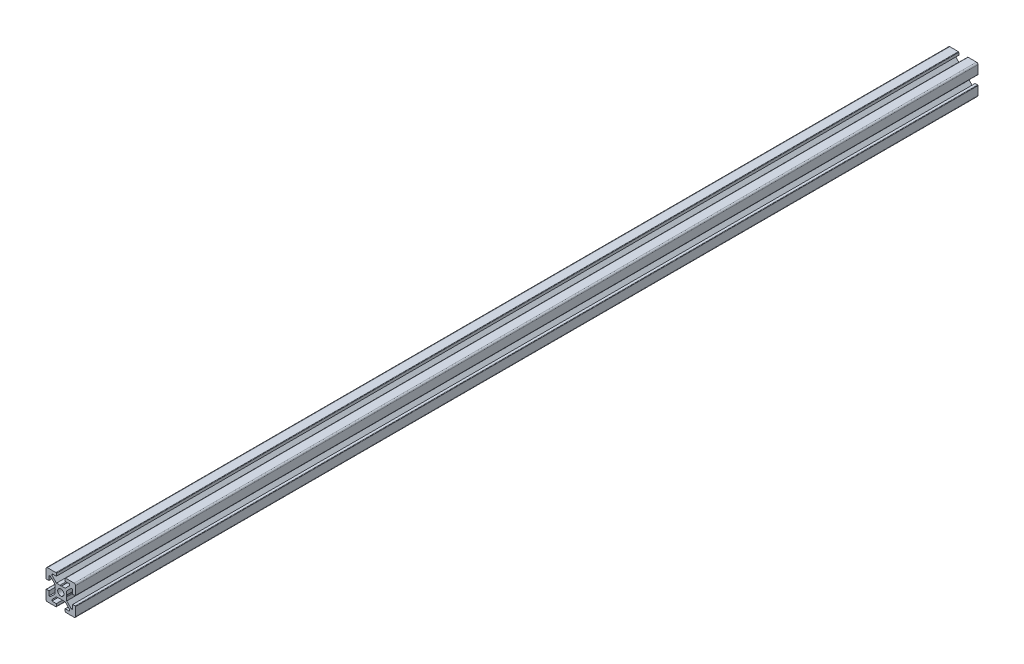
from build123d import *

# Parameters (mm, degrees)
BOSS_EXTRUDE1_DEPTH     = 609.5
SKETCH2_W               = 609.5
SKETCH2_H               = 2.1
SKETCH4_R               = 2.5
CUT_EXTRUDE1_DEPTH      = 10
CUT_EXTRUDE1_DEPTH_BACK = 10
SKETCH6_R               = 2.5
CUT_EXTRUDE2_DEPTH      = 10
CUT_EXTRUDE2_DEPTH_BACK = 10


with BuildPart() as part:
    # Sketch1 → Boss-Extrude1 (new body)
    with BuildSketch(Plane.XY):
        with BuildLine():
            Line((-10, 9), (-10, 3.29999995))
            ThreePointArc((-10, 3.29999995), (-9.912132049, 3.087867916), (-9.7, 3))
            Line((-9.7, 3), (-8, 3))
            Line((-8, 3), (-8, 6))
            Line((-8, 6), (-7.060677, 6))
            Line((-7.060677, 6), (-4, 2.93932965))
            Line((-4, 2.93932965), (-4, 0.519615242))
            Line((-4, 0.519615242), (-3.699996283, -6.437e-06))
            Line((-3.699996283, -6.437e-06), (-4, -0.519628117))
            Line((-4, -0.519628117), (-4, -2.93933725))
            Line((-4, -2.93933725), (-7.0606695, -6))
            Line((-7.0606695, -6), (-8, -6))
            Line((-8, -6), (-8, -3))
            Line((-8, -3), (-9.7, -3))
            ThreePointArc((-9.7, -3), (-9.912132049, -3.087867916), (-10, -3.29999995))
            Line((-10, -3.29999995), (-10, -9))
            ThreePointArc((-10, -9), (-9.707106781, -9.707106781), (-9, -10))
            Line((-9, -10), (-3.29999995, -10))
            ThreePointArc((-3.29999995, -10), (-3.087867916, -9.912132049), (-3, -9.7))
            Line((-3, -9.7), (-3, -8))
            Line((-3, -8), (-6, -8))
            Line((-6, -8), (-6, -7.0606515))
            Line((-6, -7.0606515), (-2.9393489, -4))
            Line((-2.9393489, -4), (-0.519615242, -4))
            Line((-0.519615242, -4), (6.437e-06, -3.699996283))
            Line((6.437e-06, -3.699996283), (0.519628117, -4))
            Line((0.519628117, -4), (2.9393227, -4))
            Line((2.9393227, -4), (6, -7.060677))
            Line((6, -7.060677), (6, -8))
            Line((6, -8), (3, -8))
            Line((3, -8), (3, -9.7))
            ThreePointArc((3, -9.7), (3.087867916, -9.912132049), (3.29999995, -10))
            Line((3.29999995, -10), (9, -10))
            ThreePointArc((9, -10), (9.707106781, -9.707106781), (10, -9))
            Line((10, -9), (10, -3.29999995))
            ThreePointArc((10, -3.29999995), (9.912132049, -3.087867916), (9.7, -3))
            Line((9.7, -3), (8, -3))
            Line((8, -3), (8, -6))
            Line((8, -6), (7.0606435, -6))
            Line((7.0606435, -6), (4, -2.9393482))
            Line((4, -2.9393482), (4, -0.519615242))
            Line((4, -0.519615242), (3.699996283, 6.437e-06))
            Line((3.699996283, 6.437e-06), (4, 0.519628117))
            Line((4, 0.519628117), (4, 2.9393401))
            Line((4, 2.9393401), (7.060651, 6))
            Line((7.060651, 6), (8, 6))
            Line((8, 6), (8, 3))
            Line((8, 3), (9.7, 3))
            ThreePointArc((9.7, 3), (9.912132049, 3.087867916), (10, 3.29999995))
            Line((10, 3.29999995), (10, 9))
            ThreePointArc((10, 9), (9.707106781, 9.707106781), (9, 10))
            Line((9, 10), (3.29999995, 10))
            ThreePointArc((3.29999995, 10), (3.087867916, 9.912132049), (3, 9.7))
            Line((3, 9.7), (3, 8))
            Line((3, 8), (6, 8))
            Line((6, 8), (6, 7.060669))
            Line((6, 7.060669), (2.9393308, 4))
            Line((2.9393308, 4), (0.519615242, 4))
            Line((0.519615242, 4), (-6.437e-06, 3.699996283))
            Line((-6.437e-06, 3.699996283), (-0.519628117, 4))
            Line((-0.519628117, 4), (-2.93935655, 4))
            Line((-2.93935655, 4), (-6, 7.0606435))
            Line((-6, 7.0606435), (-6, 8))
            Line((-6, 8), (-3, 8))
            Line((-3, 8), (-3, 9.7))
            ThreePointArc((-3, 9.7), (-3.087867966, 9.912132034), (-3.3, 10))
            Line((-3.3, 10), (-9, 10))
            ThreePointArc((-9, 10), (-9.707106781, 9.707106781), (-10, 9))
        make_face()
    extrude(amount=-BOSS_EXTRUDE1_DEPTH)

    # Sketch2 → Cut-Revolve1 (revolve, cut)
    with BuildSketch(Plane(origin=(0, 0, 0), x_dir=(0, 0, -1), z_dir=(1, 0, 0))):
        with Locations((304.75, 1.05)):
            Rectangle(SKETCH2_W, SKETCH2_H)
    revolve(axis=Axis((0, 0, -609.5), (0, 0, 1)), mode=Mode.SUBTRACT)

    # Sketch4 → Cut-Extrude1 (cut, two sides)
    with BuildSketch(Plane(origin=(0, 0, 0), x_dir=(1, 0, 0), z_dir=(0, 1, 0))) as cut_extrude1_sk:
        with Locations((-6.437e-06, 599.5)):
            Circle(SKETCH4_R)
        with Locations((-6.437e-06, 579.5)):
            Circle(SKETCH4_R)
        with Locations((-6.437e-06, 559.5)):
            Circle(SKETCH4_R)
        with Locations((-6.437e-06, 539.5)):
            Circle(SKETCH4_R)
        with Locations((-6.437e-06, 10)):
            Circle(SKETCH4_R)
        with Locations((-6.438e-06, 30)):
            Circle(SKETCH4_R)
        with Locations((-6.438e-06, 50)):
            Circle(SKETCH4_R)
        with Locations((-6.438e-06, 70)):
            Circle(SKETCH4_R)
    extrude(amount=CUT_EXTRUDE1_DEPTH, mode=Mode.SUBTRACT)
    extrude(cut_extrude1_sk.sketch, amount=-CUT_EXTRUDE1_DEPTH_BACK, mode=Mode.SUBTRACT)

    # Sketch6 → Cut-Extrude2 (cut, two sides)
    with BuildSketch(Plane(origin=(0, 0, 0), x_dir=(0, 0, -1), z_dir=(1, 0, 0))) as cut_extrude2_sk:
        with Locations((10, 0)):
            Circle(SKETCH6_R)
        with Locations((30, 0)):
            Circle(SKETCH6_R)
        with Locations((50, 0)):
            Circle(SKETCH6_R)
        with Locations((70, 0)):
            Circle(SKETCH6_R)
        with Locations((599.5, 0)):
            Circle(SKETCH6_R)
        with Locations((579.5, 0)):
            Circle(SKETCH6_R)
        with Locations((559.5, 0)):
            Circle(SKETCH6_R)
        with Locations((539.5, 0)):
            Circle(SKETCH6_R)
    extrude(amount=CUT_EXTRUDE2_DEPTH, mode=Mode.SUBTRACT)
    extrude(cut_extrude2_sk.sketch, amount=-CUT_EXTRUDE2_DEPTH_BACK, mode=Mode.SUBTRACT)


solid = part.part
